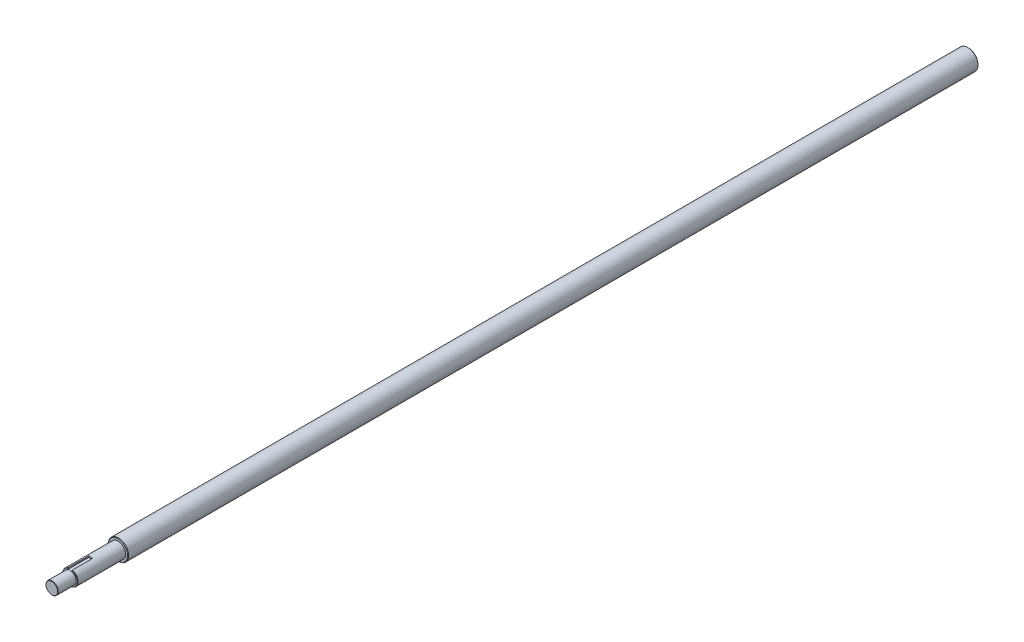
from build123d import *

# Parameters (mm, degrees)
SZKIC1_R                    = 10
DODANIE_WYCI_GNI_CIE1_DEPTH = 900
SZKIC2_R                    = 10
SZKIC2_R_2                  = 7.5
WYTNIJ_WYCI_GNI_CIE1_DEPTH  = 65
SZKIC3_R                    = 10
SZKIC3_R_2                  = 6
WYTNIJ_WYCI_GNI_CIE2_DEPTH  = 18
SFAZOWANIE1_SIZE            = 0.5
SFAZOWANIE2_SIZE            = 0.3
SFAZOWANIE3_SIZE            = 0.5
WYTNIJ_WYCI_GNI_CIE3_DEPTH  = 20


with BuildPart() as part:
    # Szkic1 → Dodanie-wyciągnięcie1 (new body)
    with BuildSketch(Plane.XY):
        Circle(SZKIC1_R)
    extrude(amount=DODANIE_WYCI_GNI_CIE1_DEPTH)

    # Szkic2 → Wytnij-wyciągnięcie1 (cut)
    with BuildSketch(Plane.XY.offset(900)):
        Circle(SZKIC2_R)
        Circle(SZKIC2_R_2, mode=Mode.SUBTRACT)
    extrude(amount=-WYTNIJ_WYCI_GNI_CIE1_DEPTH, mode=Mode.SUBTRACT)

    # Szkic3 → Wytnij-wyciągnięcie2 (cut)
    with BuildSketch(Plane.XY.offset(900)):
        Circle(SZKIC3_R)
        Circle(SZKIC3_R_2, mode=Mode.SUBTRACT)
    extrude(amount=-WYTNIJ_WYCI_GNI_CIE2_DEPTH, mode=Mode.SUBTRACT)

    # Sfazowanie1
    sfazowanie1_edges = [part.edges().sort_by_distance(p)[0] for p in [
        (-10, 0, 835),
    ]]
    chamfer(sfazowanie1_edges, length=SFAZOWANIE1_SIZE)

    # Sfazowanie2
    sfazowanie2_edges = [part.edges().sort_by_distance(p)[0] for p in [
        (-7.5, 0, 882),
        (-6, 0, 900),
    ]]
    chamfer(sfazowanie2_edges, length=SFAZOWANIE2_SIZE)

    # Sfazowanie3
    sfazowanie3_edges = [part.edges().sort_by_distance(p)[0] for p in [
        (-10, 0, 0),
    ]]
    chamfer(sfazowanie3_edges, length=SFAZOWANIE3_SIZE)

    # Szkic4 → Wytnij-wyciągnięcie3 (cut)
    with BuildSketch(Plane.XY.offset(882)):
        Polygon((0, 6), (2, 6), (2, 8.058022447), (-2, 8.058022447), (-2, 6), align=None)
    extrude(amount=-WYTNIJ_WYCI_GNI_CIE3_DEPTH, mode=Mode.SUBTRACT)


solid = part.part
